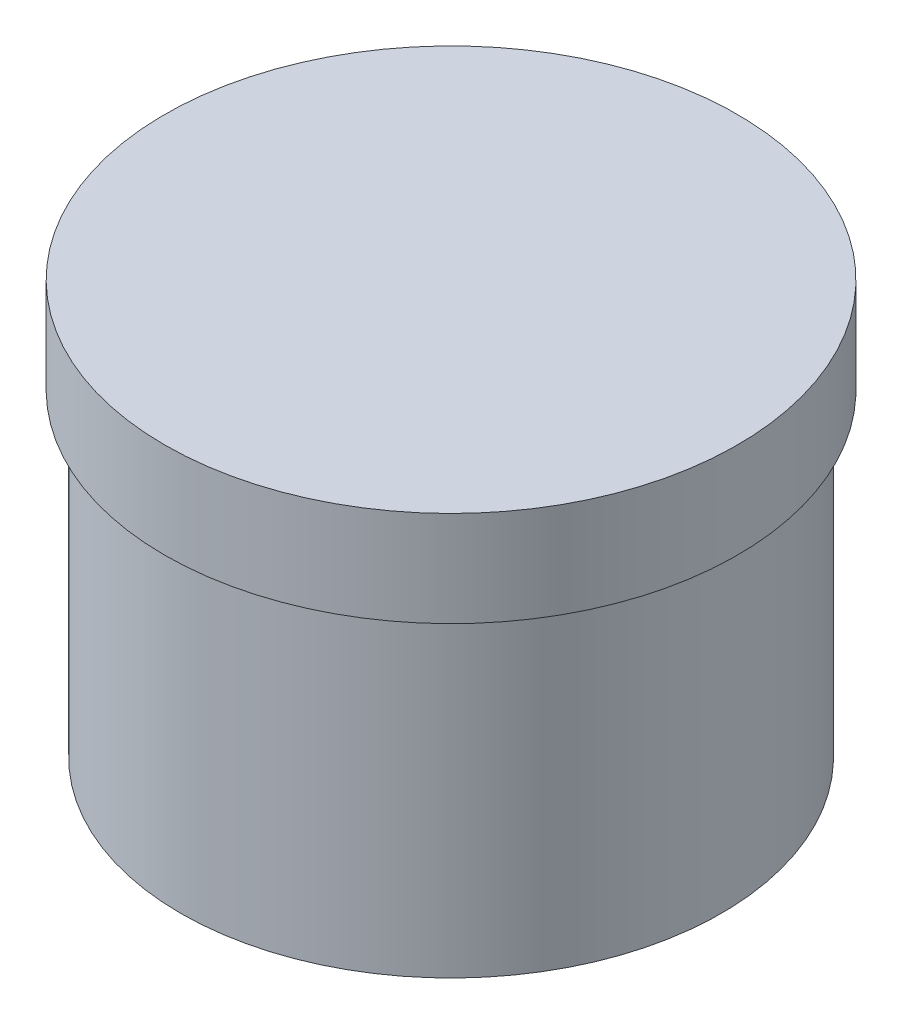
from build123d import *

# Parameters (mm, degrees)
SKETCH1_R           = 42.5
BOSS_EXTRUDE1_DEPTH = 50
SKETCH2_R           = 45
BOSS_EXTRUDE2_DEPTH = 15


with BuildPart() as part:
    # Sketch1 → Boss-Extrude1 (new body)
    with BuildSketch(Plane(origin=(0, 0, 0), x_dir=(1, 0, 0), z_dir=(0, 1, 0))):
        Circle(SKETCH1_R)
    extrude(amount=BOSS_EXTRUDE1_DEPTH)

    # Sketch2 → Boss-Extrude2 (add)
    with BuildSketch(Plane(origin=(0, 50, 0), x_dir=(1, 0, 0), z_dir=(0, 1, 0))):
        Circle(SKETCH2_R)
    extrude(amount=BOSS_EXTRUDE2_DEPTH)


solid = part.part
